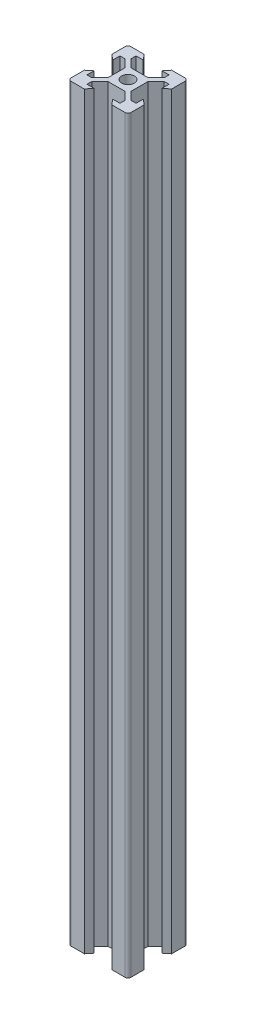
from build123d import *

# Parameters (mm, degrees)
SKETCH1_R           = 2.1
BOSS_EXTRUDE1_DEPTH = 250


with BuildPart() as part:
    # Sketch1 → Boss-Extrude1 (new body)
    with BuildSketch(Plane(origin=(0, 0, 0), x_dir=(1, 0, 0), z_dir=(0, 1, 0))):
        with BuildLine():
            Line((-5.5, 8.2), (-3.125, 8.2))
            Line((-3.125, 8.2), (-4.58, 10))
            Line((-4.58, 10), (-9, 10))
            ThreePointArc((-9, 10), (-9.707106781, 9.707106781), (-10, 9))
            Line((-10, 9), (-10, 4.58))
            Line((-10, 4.58), (-8.2, 3.125))
            Line((-8.2, 3.125), (-8.2, 5.5))
            Line((-8.2, 5.5), (-6.56, 5.5))
            Line((-6.56, 5.5), (-3.9, 2.84))
            Line((-3.9, 2.84), (-3.9, -2.84))
            Line((-3.9, -2.84), (-6.56, -5.5))
            Line((-6.56, -5.5), (-8.2, -5.5))
            Line((-8.2, -5.5), (-8.2, -3.125))
            Line((-8.2, -3.125), (-10, -4.58))
            Line((-10, -4.58), (-10, -9))
            ThreePointArc((-10, -9), (-9.707106781, -9.707106781), (-9, -10))
            Line((-9, -10), (-4.58, -10))
            Line((-4.58, -10), (-3.125, -8.2))
            Line((-3.125, -8.2), (-5.5, -8.2))
            Line((-5.5, -8.2), (-5.5, -6.56))
            Line((-5.5, -6.56), (-2.84, -3.9))
            Line((-2.84, -3.9), (2.84, -3.9))
            Line((2.84, -3.9), (5.5, -6.56))
            Line((5.5, -6.56), (5.5, -8.2))
            Line((5.5, -8.2), (3.125, -8.2))
            Line((3.125, -8.2), (4.58, -10))
            Line((4.58, -10), (9, -10))
            ThreePointArc((9, -10), (9.707106781, -9.707106781), (10, -9))
            Line((10, -9), (10, -4.58))
            Line((10, -4.58), (8.2, -3.125))
            Line((8.2, -3.125), (8.2, -5.5))
            Line((8.2, -5.5), (6.56, -5.5))
            Line((6.56, -5.5), (3.9, -2.84))
            Line((3.9, -2.84), (3.9, 2.84))
            Line((3.9, 2.84), (6.56, 5.5))
            Line((6.56, 5.5), (8.2, 5.5))
            Line((8.2, 5.5), (8.2, 3.125))
            Line((8.2, 3.125), (10, 4.58))
            Line((10, 4.58), (10, 9))
            ThreePointArc((10, 9), (9.707106781, 9.707106781), (9, 10))
            Line((9, 10), (4.58, 10))
            Line((4.58, 10), (3.125, 8.2))
            Line((3.125, 8.2), (5.5, 8.2))
            Line((5.5, 8.2), (5.5, 6.56))
            Line((5.5, 6.56), (2.84, 3.9))
            Line((2.84, 3.9), (-2.84, 3.9))
            Line((-2.84, 3.9), (-5.5, 6.56))
            Line((-5.5, 6.56), (-5.5, 8.2))
        make_face()
        Circle(SKETCH1_R, mode=Mode.SUBTRACT)
    extrude(amount=BOSS_EXTRUDE1_DEPTH)


solid = part.part
